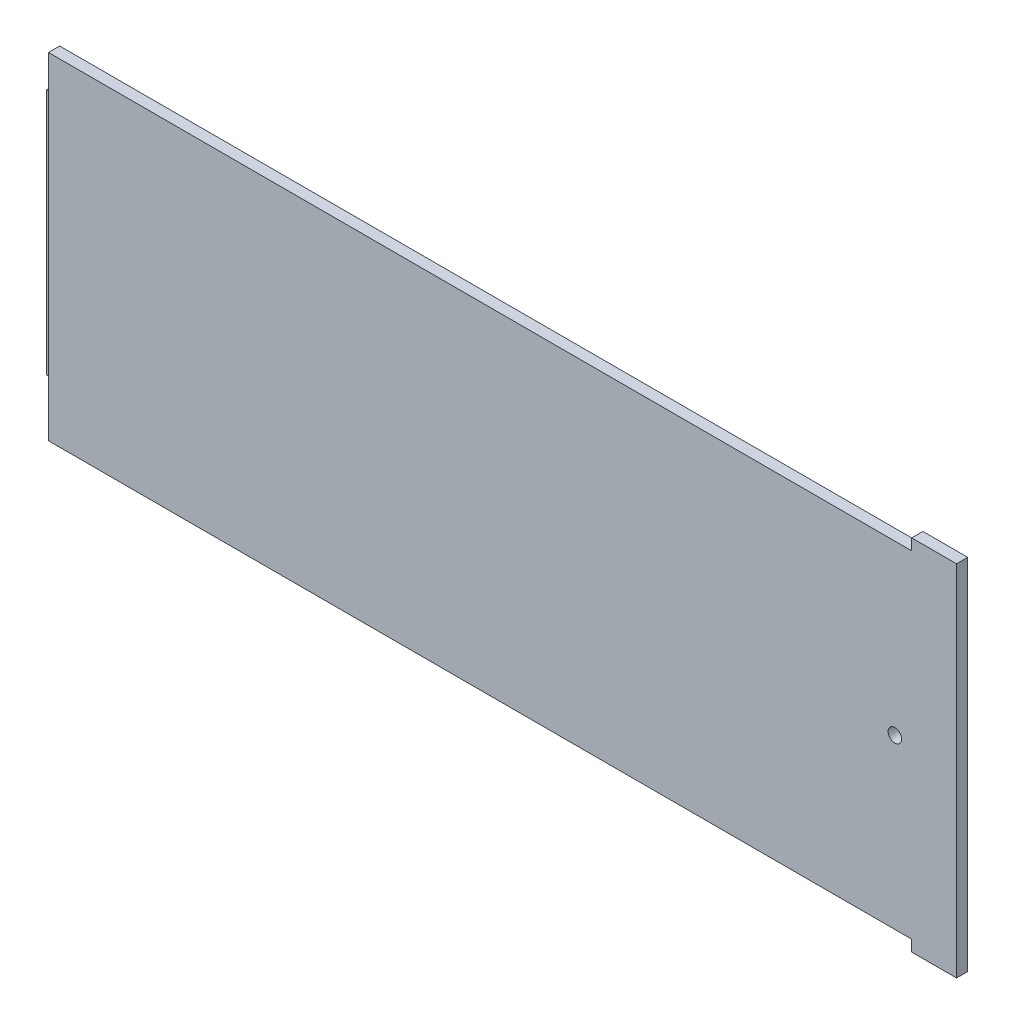
from build123d import *

# Parameters (mm, degrees)
SKETCH1_W            = 202.5
SKETCH1_H            = 75
BOSS_EXTRUDE7_DEPTH  = 2.5
SKETCH9_W            = 10
SKETCH9_H            = 2.5
BOSS_EXTRUDE8_DEPTH  = 2.5
SKETCH10_W           = 10
SKETCH10_H           = 2.5
BOSS_EXTRUDE9_DEPTH  = 2.5
SKETCH11_R           = 1.5
CUT_EXTRUDE3_DEPTH   = 2.5
SKETCH12_W           = 2.5
SKETCH12_H           = 55
BOSS_EXTRUDE10_DEPTH = 2.5
SKETCH13_W           = 2.5
SKETCH13_H           = 55
BOSS_EXTRUDE11_DEPTH = 3


with BuildPart() as part:
    # Sketch1 → Boss-Extrude7 (new body)
    with BuildSketch(Plane.XY):
        with Locations((101.25, 37.5)):
            Rectangle(SKETCH1_W, SKETCH1_H)
    extrude(amount=BOSS_EXTRUDE7_DEPTH)

    # Sketch9 → Boss-Extrude8 (add)
    with BuildSketch(Plane(origin=(0, 75, 0), x_dir=(1, 0, 0), z_dir=(0, 1, 0))):
        with Locations((197.5, -1.25)):
            Rectangle(SKETCH9_W, SKETCH9_H)
    extrude(amount=BOSS_EXTRUDE8_DEPTH)

    # Sketch10 → Boss-Extrude9 (add)
    with BuildSketch(Plane.XZ):
        with Locations((197.5, 1.25)):
            Rectangle(SKETCH10_W, SKETCH10_H)
    extrude(amount=BOSS_EXTRUDE9_DEPTH)

    # Sketch11 → Cut-Extrude3 (cut)
    with BuildSketch(Plane.XY.offset(2.5)):
        with Locations((188.75, 37.5)):
            Circle(SKETCH11_R)
    extrude(amount=-CUT_EXTRUDE3_DEPTH, mode=Mode.SUBTRACT)

    # Sketch12 → Boss-Extrude10 (add)
    with BuildSketch(Plane(origin=(0, 0, 0), x_dir=(-1, 0, 0), z_dir=(0, 0, -1))):
        with Locations((-1.25, 37.5)):
            Rectangle(SKETCH12_W, SKETCH12_H)
    extrude(amount=BOSS_EXTRUDE10_DEPTH)

    # Sketch13 → Boss-Extrude11 (add)
    with BuildSketch(Plane.ZY):
        with Locations((-1.25, 37.5)):
            Rectangle(SKETCH13_W, SKETCH13_H)
    extrude(amount=BOSS_EXTRUDE11_DEPTH)


solid = part.part
